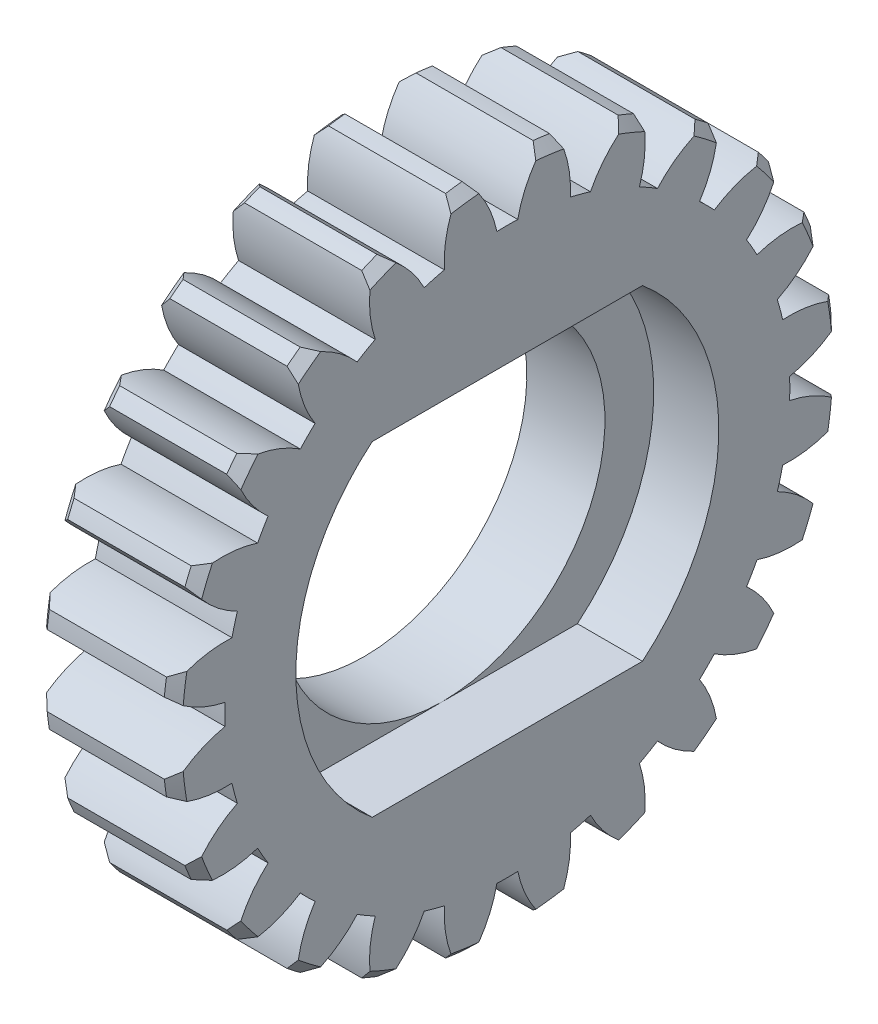
from build123d import *

# Parameters (mm, degrees)
BASPROSKE_W         = 4.2
BASPROSKE_H         = 10.3
CHAMFER_1_SIZE      = 0.3
TOOTHCUT_DEPTH      = 16.159815302
TEETHCUTS_COUNT     = 24
TEETHCUTS_ANGLE     = 345
BORSKE_R            = 1.5
BORE_DEPTH          = 50.0000508
CUT_EXTRUDE_1_DEPTH = 2
CUT_EXTRUDE_2_REACH = 16.65
SKETCH_2_R          = 5
SKETCH_3_R          = 6.1
SKETCH_3_R_2        = 5
EXTRUDE_1_DEPTH     = 0.2


with BuildPart() as part:
    # BasProSke → Base-Revolve (revolve)
    with BuildSketch(Plane(origin=(0, 0, 0), x_dir=(1, 0, 0), z_dir=(0, 1, 0)), mode=Mode.PRIVATE) as base_revolve_sk:
        with Locations((2.1, 5.15)):
            Rectangle(BASPROSKE_W, BASPROSKE_H)
    revolve(base_revolve_sk.sketch.rotate(Axis((-10, 0, 0), (1, 0, 0)), 180), axis=Axis((-10, 0, 0), (1, 0, 0)))

    # 倒角1
    chamfer_1_edges = [part.edges().sort_by_distance(p)[0] for p in [
        (0, 0, -10.3),
        (4.2, 0, -10.3),
    ]]
    chamfer(chamfer_1_edges, length=CHAMFER_1_SIZE)

    # TooCutSke → ToothCut (cut, through all)
    with BuildSketch(Plane(origin=(0, 0, 0), x_dir=(0, 0, -1), z_dir=(1, 0, 0))):
        with BuildLine():
            ThreePointArc((0.32102083, 8.675803007), (0, 8.68174016), (-0.32102083, 8.675803007))
            ThreePointArc((-0.32102083, 8.675803007), (-0.607221857, 9.507710387), (-1.091832105, 10.241967714))
            ThreePointArc((-1.091832105, 10.241967714), (0, 10.3), (1.091832105, 10.241967714))
            ThreePointArc((1.091832105, 10.241967714), (0.607221857, 9.507710387), (0.32102083, 8.675803007))
        make_face()
    toothcut = extrude(amount=TOOTHCUT_DEPTH, mode=Mode.SUBTRACT)

    # TeethCuts: ToothCut ×24 about axis
    teethcuts_axis = Axis((-10, 0, 0), (1, 0, 0))
    for i in range(1, TEETHCUTS_COUNT):
        add(toothcut.rotate(teethcuts_axis, i * TEETHCUTS_ANGLE / (TEETHCUTS_COUNT - 1)), mode=Mode.SUBTRACT)

    # BorSke → Bore (cut, symmetric)
    with BuildSketch(Plane(origin=(0, 0, 0), x_dir=(0, 0, -1), z_dir=(1, 0, 0))):
        with Locations(Location((0, 0, 0), (0, 0, 180))):
            Circle(BORSKE_R)
    extrude(amount=BORE_DEPTH, both=True, mode=Mode.SUBTRACT)

    # 草图1 → 切除-拉伸1 (cut)
    with BuildSketch(Plane(origin=(4.2, 0, 0), x_dir=(0, 0, -1), z_dir=(1, 0, 0))):
        with BuildLine():
            Line((-4.153311931, 5), (4.153311931, 5))
            ThreePointArc((4.153311931, 5), (6.5, 0), (4.153311931, -5))
            Line((4.153311931, -5), (-4.153311931, -5))
            ThreePointArc((-4.153311931, -5), (-6.5, 0), (-4.153311931, 5))
        make_face()
    extrude(amount=-CUT_EXTRUDE_1_DEPTH, mode=Mode.SUBTRACT)

    # 草图2 → 切除-拉伸2 (cut, up to next)
    with BuildSketch(Plane(origin=(2.2, 0, 0), x_dir=(0, 0, -1), z_dir=(1, 0, 0)), mode=Mode.PRIVATE) as cut_extrude_2_sk1:
        Circle(SKETCH_2_R)
    cut_extrude_2_tool1 = extrude(cut_extrude_2_sk1.sketch, amount=-CUT_EXTRUDE_2_REACH, mode=Mode.PRIVATE) & part.part
    add(cut_extrude_2_tool1.solids().sort_by_distance((2.2, 0, 0))[0], mode=Mode.SUBTRACT)

    # 草图3 → 凸台-拉伸1 (add)
    with BuildSketch(Plane.ZY):
        with Locations(Location((0, 0, 0), (0, 0, 180))):
            Circle(SKETCH_3_R)
        with Locations(Location((0, 0, 0), (0, 0, 270))):
            Circle(SKETCH_3_R_2, mode=Mode.SUBTRACT)
    extrude(amount=EXTRUDE_1_DEPTH)


solid = part.part
